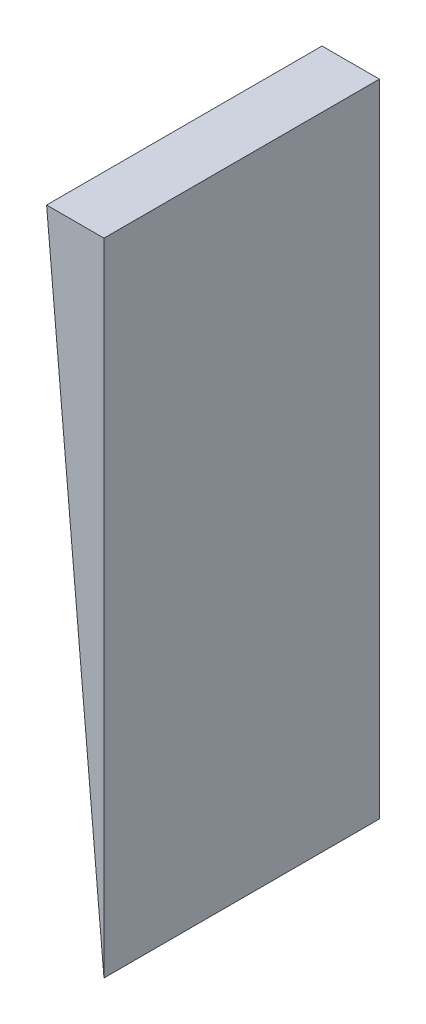
from build123d import *

# Parameters (mm, degrees)
BOSS_EXTRUDE1_DEPTH = 72


with BuildPart() as part:
    # Sketch1 → Boss-Extrude1 (new body)
    with BuildSketch(Plane.XY):
        Polygon((-15, 0), (0, -167.497927019), (0, 0), align=None)
    extrude(amount=BOSS_EXTRUDE1_DEPTH)


solid = part.part
